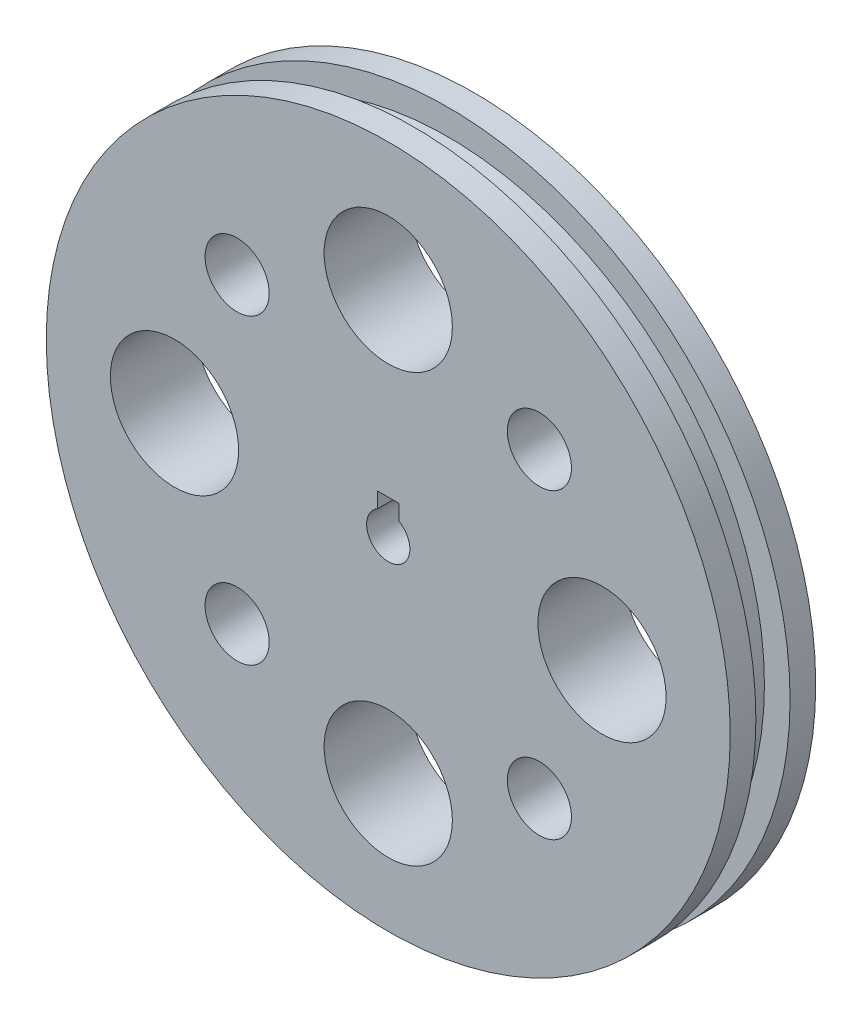
from build123d import *

# Parameters (mm, degrees)
SKETCH1_R               = 101.6
BOSS_EXTRUDE1_DEPTH     = 7.62
SKETCH4_R               = 93.98
BOSS_EXTRUDE2_DEPTH     = 10.16
SKETCH5_R               = 101.6
BOSS_EXTRUDE3_DEPTH     = 7.62
CUT_EXTRUDE1_DEPTH      = 145.78
CUT_EXTRUDE1_DEPTH_BACK = 25.4
SKETCH2_R               = 19.05
SKETCH2_R_2             = 9.525
CUT_EXTRUDE2_DEPTH      = 25.4
CUT_EXTRUDE3_DEPTH      = 145.78
CUT_EXTRUDE3_DEPTH_BACK = 145.78


with BuildPart() as part:
    # Sketch1 → Boss-Extrude1 (new body)
    with BuildSketch(Plane.XY):
        Circle(SKETCH1_R)
    extrude(amount=BOSS_EXTRUDE1_DEPTH)

    # Sketch4 → Boss-Extrude2 (add)
    with BuildSketch(Plane.XY.offset(7.62)):
        Circle(SKETCH4_R)
    extrude(amount=BOSS_EXTRUDE2_DEPTH)

    # Sketch5 → Boss-Extrude3 (add)
    with BuildSketch(Plane.XY.offset(17.78)):
        Circle(SKETCH5_R)
    extrude(amount=BOSS_EXTRUDE3_DEPTH)

    # Sketch2 → Cut-Extrude1 (cut, two sides: drawn at the far end of the back side and taken through both)
    with BuildSketch(Plane.XY.offset(7.62).offset(-CUT_EXTRUDE1_DEPTH_BACK)):
        with Locations((-63.5, 0)):
            Circle(SKETCH2_R)
        with Locations((-44.901280605, 44.901280605)):
            Circle(SKETCH2_R_2)
        with Locations((0, 63.5)):
            Circle(SKETCH2_R)
        with Locations((44.901280605, 44.901280605)):
            Circle(SKETCH2_R_2)
        with Locations((63.5, 0)):
            Circle(SKETCH2_R)
        with Locations((44.901280605, -44.901280605)):
            Circle(SKETCH2_R_2)
        with Locations((0, -63.5)):
            Circle(SKETCH2_R)
        with Locations((-44.901280605, -44.901280605)):
            Circle(SKETCH2_R_2)
    extrude(amount=CUT_EXTRUDE1_DEPTH + CUT_EXTRUDE1_DEPTH_BACK, mode=Mode.SUBTRACT)

    # Sketch3 → Cut-Extrude2 (cut)
    with BuildSketch(Plane.XY.offset(7.62)):
        with BuildLine():
            Line((-3.175, 5.588), (-3.175, 10.16))
            Line((-3.175, 10.16), (3.175, 10.16))
            Line((3.175, 10.16), (3.175, 5.588))
            ThreePointArc((3.175, 5.588), (0, -6.427003112), (-3.175, 5.588))
        make_face()
    extrude(amount=-CUT_EXTRUDE2_DEPTH, mode=Mode.SUBTRACT)

    # Sketch3_2 → Cut-Extrude3 (cut, two sides: drawn at the far end of the back side and taken through both)
    with BuildSketch(Plane.XY.offset(7.62).offset(-CUT_EXTRUDE3_DEPTH_BACK)):
        with BuildLine():
            Line((-3.175, 5.588), (-3.175, 10.16))
            Line((-3.175, 10.16), (3.175, 10.16))
            Line((3.175, 10.16), (3.175, 5.588))
            ThreePointArc((3.175, 5.588), (0, -6.427003112), (-3.175, 5.588))
        make_face()
    extrude(amount=CUT_EXTRUDE3_DEPTH + CUT_EXTRUDE3_DEPTH_BACK, mode=Mode.SUBTRACT)


solid = part.part
